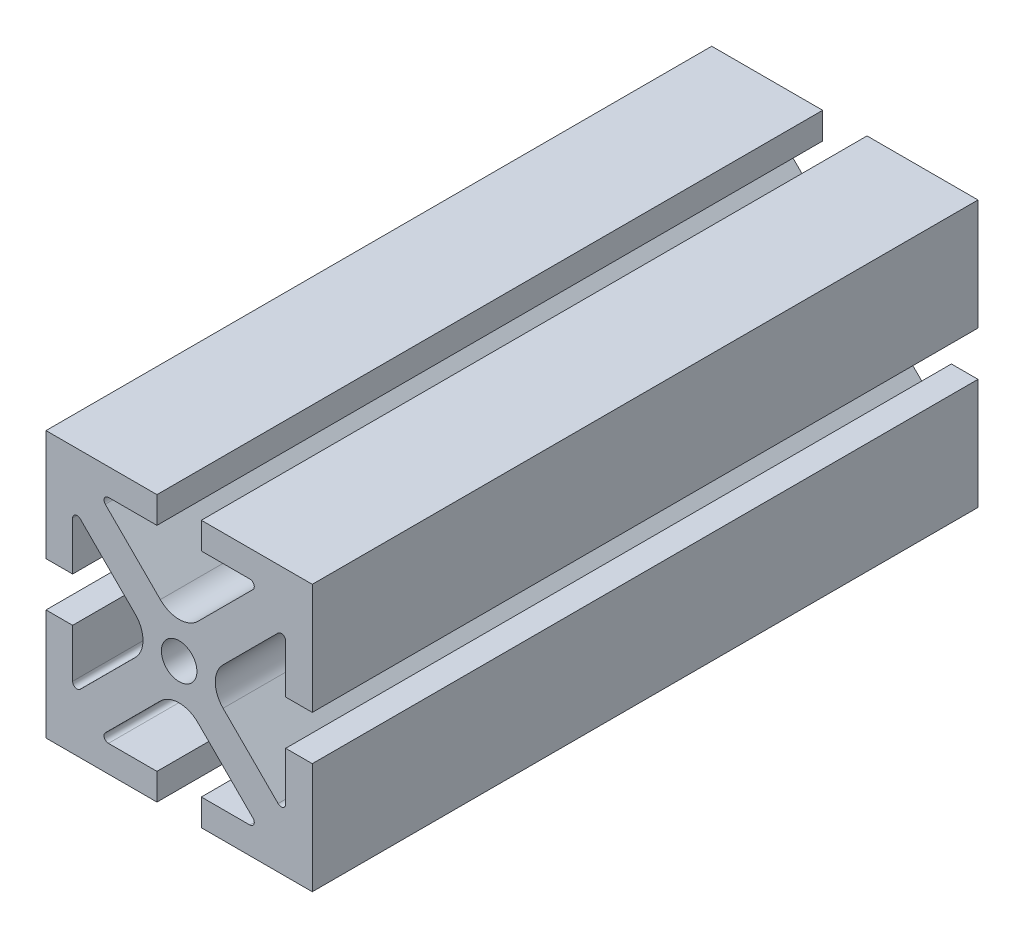
from build123d import *

# Parameters (mm, degrees)
BOSS_EXTRUDE1_DEPTH = 150
SKETCH2_R           = 3.75
CUT_EXTRUDE1_DEPTH  = 151
SKETCH3_R           = 4
CUT_EXTRUDE2_DEPTH  = 61
SKETCH5_R           = 4
CUT_EXTRUDE5_DEPTH  = 20
SKETCH6_R           = 4
CUT_EXTRUDE6_DEPTH  = 20
SCALE1_SCALE        = 0.5


with BuildPart() as part:
    # Sketch1 → Boss-Extrude1 (new body)
    with BuildSketch(Plane.XY):
        with BuildLine():
            Line((-5, 30), (-5, 24))
            Line((-5, 24), (-15.928932188, 24))
            ThreePointArc((-15.928932188, 24), (-16.852811721, 23.382683432), (-16.636038969, 22.292893219))
            Line((-16.636038969, 22.292893219), (-4.242640687, 9.899494937))
            ThreePointArc((-4.242640687, 9.899494937), (0, 8.142135624), (4.242640687, 9.899494937))
            Line((4.242640687, 9.899494937), (16.636038969, 22.292893219))
            ThreePointArc((16.636038969, 22.292893219), (16.852811721, 23.382683432), (15.928932188, 24))
            Line((15.928932188, 24), (5, 24))
            Line((5, 24), (5, 30))
            Line((5, 30), (30, 30))
            Line((30, 30), (30, 5))
            Line((30, 5), (24, 5))
            Line((24, 5), (24, 15.928932188))
            ThreePointArc((24, 15.928932188), (23.382683432, 16.852811721), (22.292893219, 16.636038969))
            Line((22.292893219, 16.636038969), (9.899494937, 4.242640687))
            ThreePointArc((9.899494937, 4.242640687), (8.142135624, 0), (9.899494937, -4.242640687))
            Line((9.899494937, -4.242640687), (22.292893219, -16.636038969))
            ThreePointArc((22.292893219, -16.636038969), (23.382683432, -16.852811721), (24, -15.928932188))
            Line((24, -15.928932188), (24, -5))
            Line((24, -5), (30, -5))
            Line((30, -5), (30, -30))
            Line((30, -30), (5, -30))
            Line((5, -30), (5, -24))
            Line((5, -24), (15.928932188, -24))
            ThreePointArc((15.928932188, -24), (16.852811721, -23.382683432), (16.636038969, -22.292893219))
            Line((16.636038969, -22.292893219), (4.242640687, -9.899494937))
            ThreePointArc((4.242640687, -9.899494937), (0, -8.142135624), (-4.242640687, -9.899494937))
            Line((-4.242640687, -9.899494937), (-16.636038969, -22.292893219))
            ThreePointArc((-16.636038969, -22.292893219), (-16.852811721, -23.382683432), (-15.928932188, -24))
            Line((-15.928932188, -24), (-5, -24))
            Line((-5, -24), (-5, -30))
            Line((-5, -30), (-30, -30))
            Line((-30, -30), (-30, -5))
            Line((-30, -5), (-24, -5))
            Line((-24, -5), (-24, -15.928932188))
            ThreePointArc((-24, -15.928932188), (-23.382683432, -16.852811721), (-22.292893219, -16.636038969))
            Line((-22.292893219, -16.636038969), (-9.899494937, -4.242640687))
            ThreePointArc((-9.899494937, -4.242640687), (-8.142135624, 0), (-9.899494937, 4.242640687))
            Line((-9.899494937, 4.242640687), (-22.292893219, 16.636038969))
            ThreePointArc((-22.292893219, 16.636038969), (-23.382683432, 16.852811721), (-24, 15.928932188))
            Line((-24, 15.928932188), (-24, 5))
            Line((-24, 5), (-30, 5))
            Line((-30, 5), (-30, 30))
            Line((-30, 30), (-5, 30))
        make_face()
    extrude(amount=BOSS_EXTRUDE1_DEPTH)

    # Sketch2 → Cut-Extrude1 (cut, through all)
    with BuildSketch(Plane(origin=(0, 0, 0), x_dir=(-1, 0, 0), z_dir=(0, 0, -1))):
        Circle(SKETCH2_R)
    extrude(amount=-CUT_EXTRUDE1_DEPTH, mode=Mode.SUBTRACT)

    # Sketch3 → Cut-Extrude2 (cut, through all)
    with BuildSketch(Plane.ZY.offset(30)):
        with Locations(Location((75, 0, 0), (0, 0, 270))):  # turned: the seam where the file's is
            Circle(SKETCH3_R)
        with Locations(Location((30, 0, 0), (0, 0, 270))):  # turned: the seam where the file's is
            Circle(SKETCH3_R)
    extrude(amount=-CUT_EXTRUDE2_DEPTH, mode=Mode.SUBTRACT)

    # Sketch5 → Cut-Extrude5 (cut)
    with BuildSketch(Plane(origin=(0, 0, 0), x_dir=(-1, 0, 0), z_dir=(0, 0, -1))):
        Circle(SKETCH5_R)
    extrude(amount=-CUT_EXTRUDE5_DEPTH, mode=Mode.SUBTRACT)

    # Sketch6 → Cut-Extrude6 (cut)
    with BuildSketch(Plane.XY.offset(150)):
        with Locations(Location((0, 0, 0), (0, 0, 180))):  # turned: the seam where the file's is
            Circle(SKETCH6_R)
    extrude(amount=-CUT_EXTRUDE6_DEPTH, mode=Mode.SUBTRACT)


with BuildPart() as part_1:
    # Scale1: scaled about (5.21e-07, -1.92e-07, 75.081821445)
    add(part.part.scale(SCALE1_SCALE).moved(Location((2.6e-07, -9.6e-08, 37.540910723))))


solid = part_1.part
